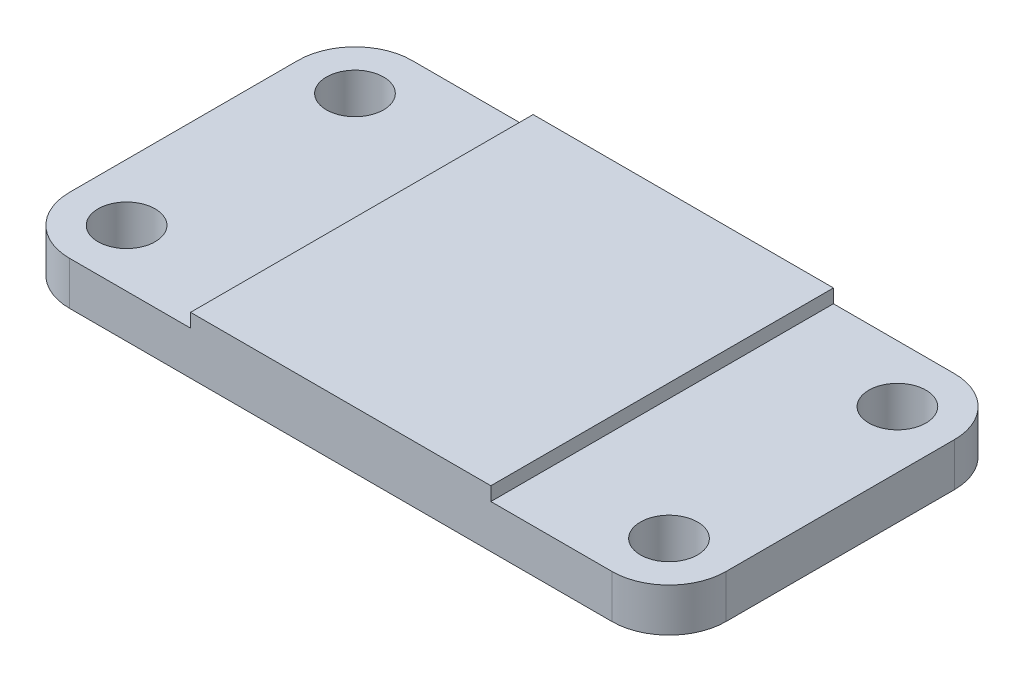
from build123d import *

# Parameters (mm, degrees)
SKETCH1_W                  = 146.05
SKETCH1_H                  = 76.2
BOSS_EXTRUDE1_DEPTH        = 9.652
SKETCH3_W                  = 66.802
SKETCH3_H                  = 76.2
BOSS_EXTRUDE2_DEPTH        = 3.048
FILLET1_R                  = 12.7
F_1_4_0_5_DIAMETER_HOLE1_D = 12.7


with BuildPart() as part:
    # Sketch1 → Boss-Extrude1 (new body)
    with BuildSketch(Plane(origin=(0, 0, 0), x_dir=(1, 0, 0), z_dir=(0, 1, 0))):
        Rectangle(SKETCH1_W, SKETCH1_H)
    extrude(amount=BOSS_EXTRUDE1_DEPTH)

    # Sketch3 → Boss-Extrude2 (add)
    with BuildSketch(Plane(origin=(0, 9.652, 0), x_dir=(1, 0, 0), z_dir=(0, 1, 0))):
        Rectangle(SKETCH3_W, SKETCH3_H)
    extrude(amount=BOSS_EXTRUDE2_DEPTH)

    # Fillet1
    fillet1_edges = [part.edges().sort_by_distance(p)[0] for p in [
        (73.025, 4.826, -38.1),
        (73.025, 4.826, 38.1),
        (-73.025, 4.826, 38.1),
        (-73.025, 4.826, -38.1),
    ]]
    fillet(fillet1_edges, radius=FILLET1_R)

    # 1_4 _0.5_ Diameter Hole1 (through all)
    with Locations(Plane(origin=(0, 9.652, 0), x_dir=(1, 0, 0), z_dir=(0, 1, 0))):
        with Locations((-60.325, 25.4), (-60.325, -25.4), (60.325, -25.4), (60.325, 25.4)):
            Hole(F_1_4_0_5_DIAMETER_HOLE1_D / 2)


solid = part.part
